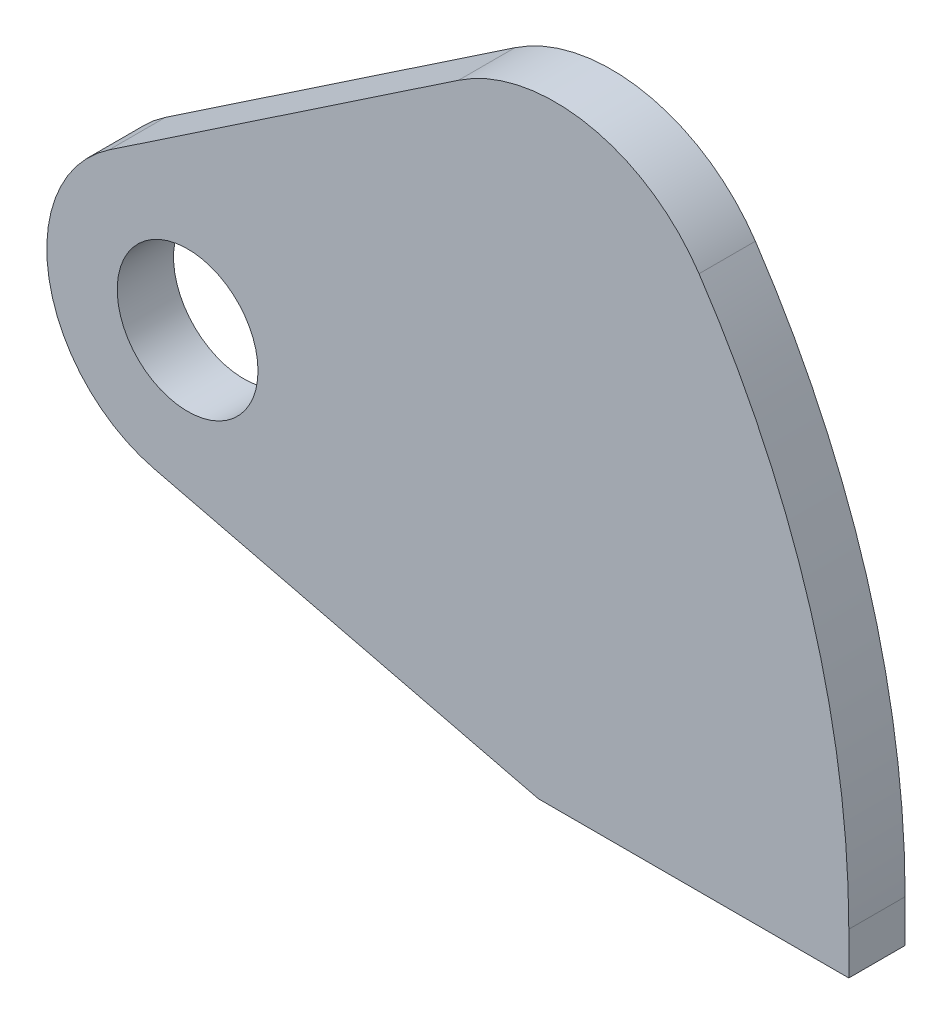
from build123d import *

# Parameters (mm, degrees)
SKETCH_1_R      = 5
EXTRUDE_1_DEPTH = 4


with BuildPart() as part:
    # Эскиз1 → Бобышка-Вытянуть1 (new body)
    with BuildSketch(Plane.XY):
        with BuildLine():
            Line((10.65, 0), (10.65, -3))
            Line((10.65, -3), (-11.397789553, -3))
            Line((-11.397789553, -3), (-38.677904755, 3.651503117))
            ThreePointArc((-38.677904755, 3.651503117), (-46.153775079, 11.6113462), (-41.890065439, 21.664630197))
            Line((-41.890065439, 21.664630197), (-17.065107401, 38.361673869))
            ThreePointArc((-17.065107401, 38.361673869), (-7.827814909, 40.223299164), (0.014835138, 34.999692982))
            ThreePointArc((0.014835138, 34.999692982), (7.932514626, 18.289923732), (10.65, 0))
        make_face()
        with Locations((-36.309076923, 13.366885492)):
            Circle(SKETCH_1_R, mode=Mode.SUBTRACT)
    extrude(amount=EXTRUDE_1_DEPTH)


solid = part.part
